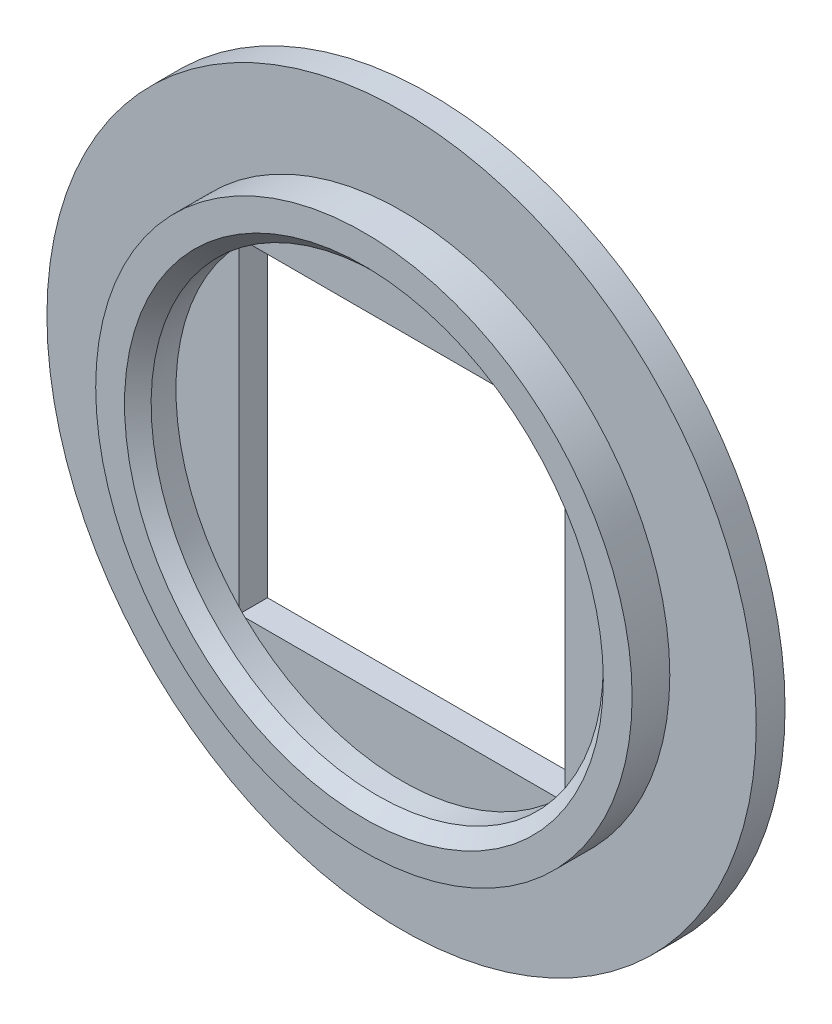
from build123d import *

# Parameters (mm, degrees)
SKETCH_1_R          = 8
EXTRUDE_1_DEPTH     = 0.65
EXTRUDE_START       = 0.65
SKETCH_2_R          = 6.05
SKETCH_2_R_2        = 5.1
EXTRUDE_2_DEPTH     = 0.85
CUT_EXTRUDE_START   = 0.65
SKETCH_3_R          = 5.1
CUT_EXTRUDE_1_DEPTH = 0.01
CUT_EXTRUDE_2_DEPTH = 0.64
CHAMFER_1_SIZE      = 0.3


with BuildPart() as part:
    # 草图1 → 凸台-拉伸1 (new body)
    with BuildSketch(Plane.XY):
        Circle(SKETCH_1_R)
    extrude(amount=EXTRUDE_1_DEPTH)

    # 草图2 → 凸台-拉伸2 (add)
    with BuildSketch(Plane.XY.offset(EXTRUDE_START)):
        Circle(SKETCH_2_R)
        Circle(SKETCH_2_R_2, mode=Mode.SUBTRACT)
    extrude(amount=EXTRUDE_2_DEPTH)

    # 草图3 → 切除-拉伸1 (cut)
    with BuildSketch(Plane.XY.offset(CUT_EXTRUDE_START)):
        Circle(SKETCH_3_R)
    extrude(amount=-CUT_EXTRUDE_1_DEPTH, mode=Mode.SUBTRACT)

    # 草图4 → 切除-拉伸2 (cut)
    with BuildSketch(Plane.XY):
        Polygon((3.675, 3.675), (3.675, -3.675), (-3.675, -3.675), (-3.675, 0), (-3.675, 3.675), align=None)
    extrude(amount=CUT_EXTRUDE_2_DEPTH, mode=Mode.SUBTRACT)

    # 倒角1
    chamfer_1_edges = [part.edges().sort_by_distance(p)[0] for p in [
        (-5.1, 0, 1.5),
    ]]
    chamfer(chamfer_1_edges, length=CHAMFER_1_SIZE)


solid = part.part
